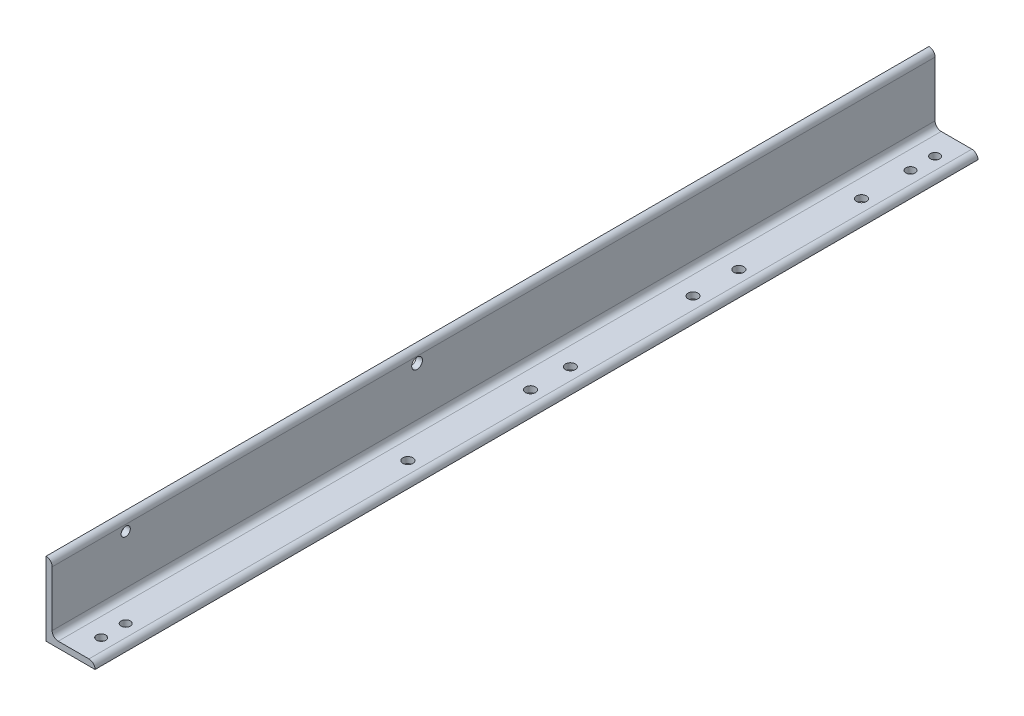
from build123d import *

# Parameters (mm, degrees)
BOSS_EXTRUDE1_DEPTH             = 914.4
CUT_EXTRUDE2_REACH              = 14.7
SKETCH3_R                       = 9.525
SKETCH3_R_2                     = 10.31875
F_3_4_0_75_DIAMETER_HOLE1_D     = 19.05
F_3_4_0_75_DIAMETER_HOLE1_DEPTH = 12.7
SKETCH6_R                       = 11.1125
CUT_EXTRUDE3_DEPTH              = 13.7


with BuildPart() as part:
    # Sketch1 → Boss-Extrude1 (new body, symmetric)
    with BuildSketch(Plane.XY):
        with BuildLine():
            Line((0, 0), (0, 152.4))
            Line((0, 152.4), (0.00508, 152.4))
            ThreePointArc((0.00508, 152.4), (8.981744019, 148.681744019), (12.7, 139.70508))
            Line((12.7, 139.70508), (12.7, 25.4))
            ThreePointArc((12.7, 25.4), (16.419743879, 16.419743879), (25.4, 12.7))
            Line((25.4, 12.7), (88.90508, 12.7))
            ThreePointArc((88.90508, 12.7), (97.881744019, 8.981744019), (101.6, 0.00508))
            Line((101.6, 0.00508), (101.6, 0))
            Line((101.6, 0), (0, 0))
        make_face()
    extrude(amount=BOSS_EXTRUDE1_DEPTH, both=True)

    # Sketch3 → Cut-Extrude2 (cut, up to next)
    with BuildSketch(Plane(origin=(0, 12.7, 0), x_dir=(1, 0, 0), z_dir=(0, 1, 0)), mode=Mode.PRIVATE) as cut_extrude2_sk1:
        with Locations((63.5, -863.6)):
            Circle(SKETCH3_R)
    cut_extrude2_tool1 = extrude(cut_extrude2_sk1.sketch, amount=-CUT_EXTRUDE2_REACH, mode=Mode.PRIVATE) & part.part
    add(cut_extrude2_tool1.solids().sort_by_distance((63.5, 12.7, 863.6))[0], mode=Mode.SUBTRACT)
    # Sketch3 → Cut-Extrude2 (cut, up to next)
    with BuildSketch(Plane(origin=(0, 12.7, 0), x_dir=(1, 0, 0), z_dir=(0, 1, 0)), mode=Mode.PRIVATE) as cut_extrude2_sk2:
        with Locations((63.5, 863.6)):
            Circle(SKETCH3_R)
    cut_extrude2_tool2 = extrude(cut_extrude2_sk2.sketch, amount=-CUT_EXTRUDE2_REACH, mode=Mode.PRIVATE) & part.part
    add(cut_extrude2_tool2.solids().sort_by_distance((63.5, 12.7, -863.6))[0], mode=Mode.SUBTRACT)
    # Sketch3 → Cut-Extrude2 (cut, up to next)
    with BuildSketch(Plane(origin=(0, 12.7, 0), x_dir=(1, 0, 0), z_dir=(0, 1, 0)), mode=Mode.PRIVATE) as cut_extrude2_sk3:
        with Locations((63.5, 25.654)):
            Circle(SKETCH3_R_2)
    cut_extrude2_tool3 = extrude(cut_extrude2_sk3.sketch, amount=-CUT_EXTRUDE2_REACH, mode=Mode.PRIVATE) & part.part
    add(cut_extrude2_tool3.solids().sort_by_distance((63.5, 12.7, -25.654))[0], mode=Mode.SUBTRACT)
    # Sketch3 → Cut-Extrude2 (cut, up to next)
    with BuildSketch(Plane(origin=(0, 12.7, 0), x_dir=(1, 0, 0), z_dir=(0, 1, 0)), mode=Mode.PRIVATE) as cut_extrude2_sk4:
        with Locations((63.5, -812.8)):
            Circle(SKETCH3_R)
    cut_extrude2_tool4 = extrude(cut_extrude2_sk4.sketch, amount=-CUT_EXTRUDE2_REACH, mode=Mode.PRIVATE) & part.part
    add(cut_extrude2_tool4.solids().sort_by_distance((63.5, 12.7, 812.8))[0], mode=Mode.SUBTRACT)
    # Sketch3 → Cut-Extrude2 (cut, up to next)
    with BuildSketch(Plane(origin=(0, 12.7, 0), x_dir=(1, 0, 0), z_dir=(0, 1, 0)), mode=Mode.PRIVATE) as cut_extrude2_sk5:
        with Locations((63.5, 711.2)):
            Circle(SKETCH3_R_2)
    cut_extrude2_tool5 = extrude(cut_extrude2_sk5.sketch, amount=-CUT_EXTRUDE2_REACH, mode=Mode.PRIVATE) & part.part
    add(cut_extrude2_tool5.solids().sort_by_distance((63.5, 12.7, -711.2))[0], mode=Mode.SUBTRACT)
    # Sketch3 → Cut-Extrude2 (cut, up to next)
    with BuildSketch(Plane(origin=(0, 12.7, 0), x_dir=(1, 0, 0), z_dir=(0, 1, 0)), mode=Mode.PRIVATE) as cut_extrude2_sk6:
        with Locations((63.5, 457.2)):
            Circle(SKETCH3_R_2)
    cut_extrude2_tool6 = extrude(cut_extrude2_sk6.sketch, amount=-CUT_EXTRUDE2_REACH, mode=Mode.PRIVATE) & part.part
    add(cut_extrude2_tool6.solids().sort_by_distance((63.5, 12.7, -457.2))[0], mode=Mode.SUBTRACT)
    # Sketch3 → Cut-Extrude2 (cut, up to next)
    with BuildSketch(Plane(origin=(0, 12.7, 0), x_dir=(1, 0, 0), z_dir=(0, 1, 0)), mode=Mode.PRIVATE) as cut_extrude2_sk7:
        with Locations((63.5, -228.346)):
            Circle(SKETCH3_R_2)
    cut_extrude2_tool7 = extrude(cut_extrude2_sk7.sketch, amount=-CUT_EXTRUDE2_REACH, mode=Mode.PRIVATE) & part.part
    add(cut_extrude2_tool7.solids().sort_by_distance((63.5, 12.7, 228.346))[0], mode=Mode.SUBTRACT)
    # Sketch3 → Cut-Extrude2 (cut, up to next)
    with BuildSketch(Plane(origin=(0, 12.7, 0), x_dir=(1, 0, 0), z_dir=(0, 1, 0)), mode=Mode.PRIVATE) as cut_extrude2_sk8:
        with Locations((63.5, 362.204)):
            Circle(SKETCH3_R_2)
    cut_extrude2_tool8 = extrude(cut_extrude2_sk8.sketch, amount=-CUT_EXTRUDE2_REACH, mode=Mode.PRIVATE) & part.part
    add(cut_extrude2_tool8.solids().sort_by_distance((63.5, 12.7, -362.204))[0], mode=Mode.SUBTRACT)
    # Sketch3 → Cut-Extrude2 (cut, up to next)
    with BuildSketch(Plane(origin=(0, 12.7, 0), x_dir=(1, 0, 0), z_dir=(0, 1, 0)), mode=Mode.PRIVATE) as cut_extrude2_sk9:
        with Locations((63.5, 108.204)):
            Circle(SKETCH3_R_2)
    cut_extrude2_tool9 = extrude(cut_extrude2_sk9.sketch, amount=-CUT_EXTRUDE2_REACH, mode=Mode.PRIVATE) & part.part
    add(cut_extrude2_tool9.solids().sort_by_distance((63.5, 12.7, -108.204))[0], mode=Mode.SUBTRACT)
    # Sketch3 → Cut-Extrude2 (cut, up to next)
    with BuildSketch(Plane(origin=(0, 12.7, 0), x_dir=(1, 0, 0), z_dir=(0, 1, 0)), mode=Mode.PRIVATE) as cut_extrude2_sk10:
        with Locations((63.5, 812.8)):
            Circle(SKETCH3_R)
    cut_extrude2_tool10 = extrude(cut_extrude2_sk10.sketch, amount=-CUT_EXTRUDE2_REACH, mode=Mode.PRIVATE) & part.part
    add(cut_extrude2_tool10.solids().sort_by_distance((63.5, 12.7, -812.8))[0], mode=Mode.SUBTRACT)

    # 3/4 (0.75) Diameter Hole1
    with Locations(Plane(origin=(12.7, 0, 0), x_dir=(0, 0, -1), z_dir=(1, 0, 0))):
        with Locations((-762, 127)):
            Hole(F_3_4_0_75_DIAMETER_HOLE1_D / 2, depth=F_3_4_0_75_DIAMETER_HOLE1_DEPTH)

    # Sketch6 → Cut-Extrude3 (cut, through all)
    with BuildSketch(Plane(origin=(12.7, 0, 0), x_dir=(0, 0, -1), z_dir=(1, 0, 0))):
        with Locations((-158.496, 127)):
            Circle(SKETCH6_R)
    extrude(amount=-CUT_EXTRUDE3_DEPTH, mode=Mode.SUBTRACT)


solid = part.part
